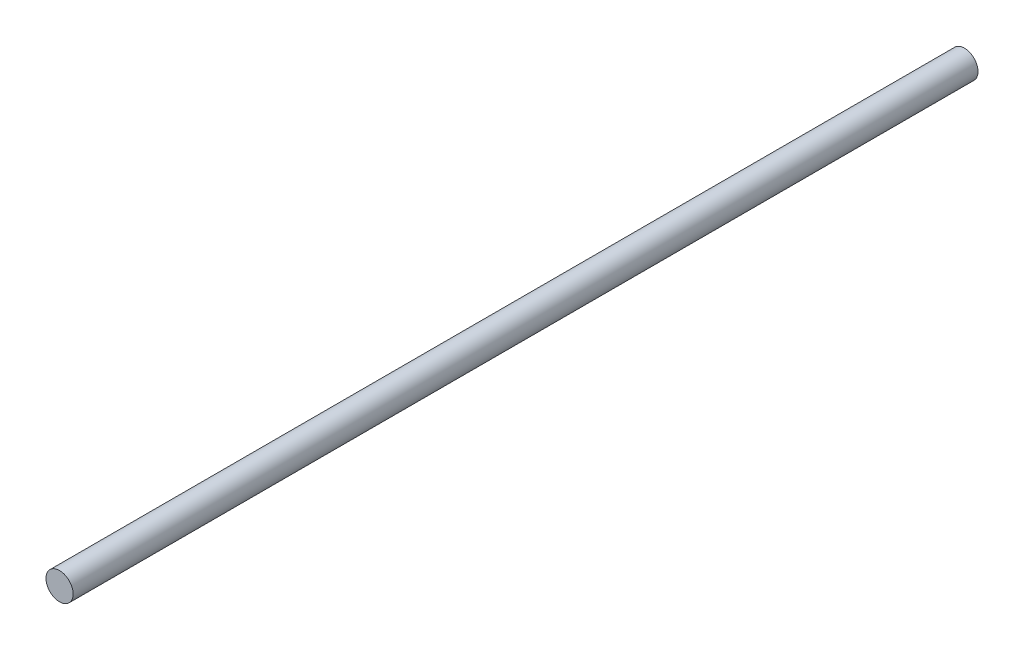
from build123d import *

# Parameters (mm, degrees)
SKETCH1_R           = 6
BOSS_EXTRUDE1_DEPTH = 400


with BuildPart() as part:
    # Sketch1 → Boss-Extrude1 (new body)
    with BuildSketch(Plane.XY):
        Circle(SKETCH1_R)
    extrude(amount=BOSS_EXTRUDE1_DEPTH)


solid = part.part
